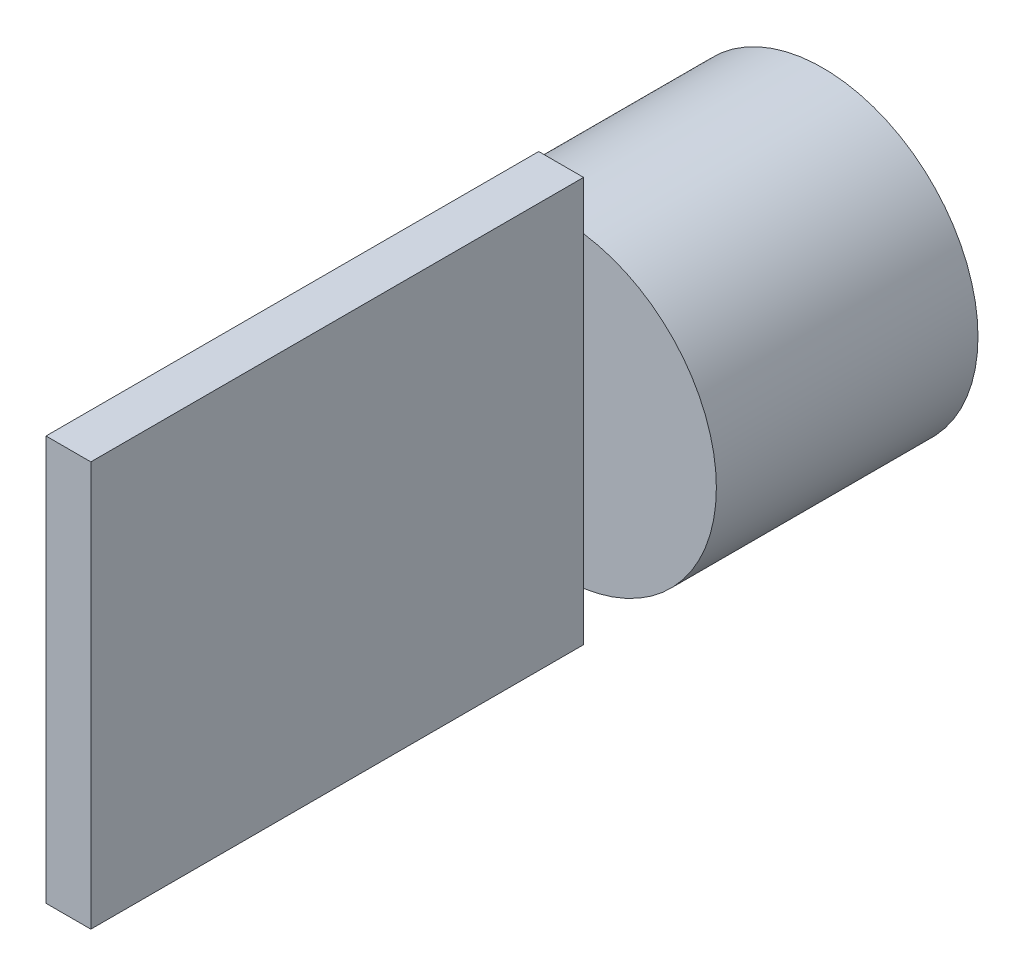
from build123d import *

# Parameters (mm, degrees)
SKIZZE1_R                       = 35.6
AUFSATZ_LINEAR_AUSTRAGEN1_DEPTH = 60
SKIZZE2_W                       = 10.283106272
SKIZZE2_H                       = 92.818564508
AUFSATZ_LINEAR_AUSTRAGEN2_DEPTH = 113


with BuildPart() as part:
    # Skizze1 → Aufsatz-Linear austragen1 (new body)
    with BuildSketch(Plane.XY):
        Circle(SKIZZE1_R)
    extrude(amount=AUFSATZ_LINEAR_AUSTRAGEN1_DEPTH)

    # Skizze2 → Aufsatz-Linear austragen2 (add)
    with BuildSketch(Plane.XY.offset(60)):
        Rectangle(SKIZZE2_W, SKIZZE2_H)
    extrude(amount=AUFSATZ_LINEAR_AUSTRAGEN2_DEPTH)


solid = part.part
